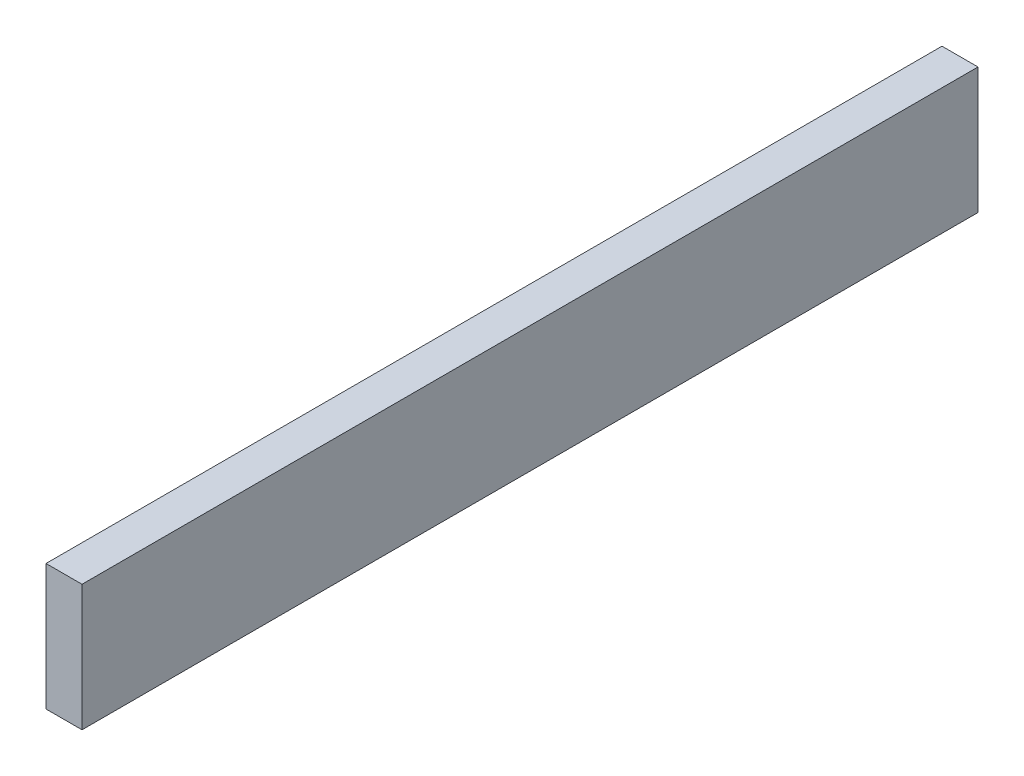
from build123d import *

# Parameters (mm, degrees)
SKETCH1_W           = 99.5
SKETCH1_H           = 14
BOSS_EXTRUDE1_DEPTH = 4


with BuildPart() as part:
    # Sketch1 → Boss-Extrude1 (new body)
    with BuildSketch(Plane(origin=(0, 0, 0), x_dir=(0, 0, -1), z_dir=(1, 0, 0))):
        Rectangle(SKETCH1_W, SKETCH1_H)
    extrude(amount=-BOSS_EXTRUDE1_DEPTH)


solid = part.part
